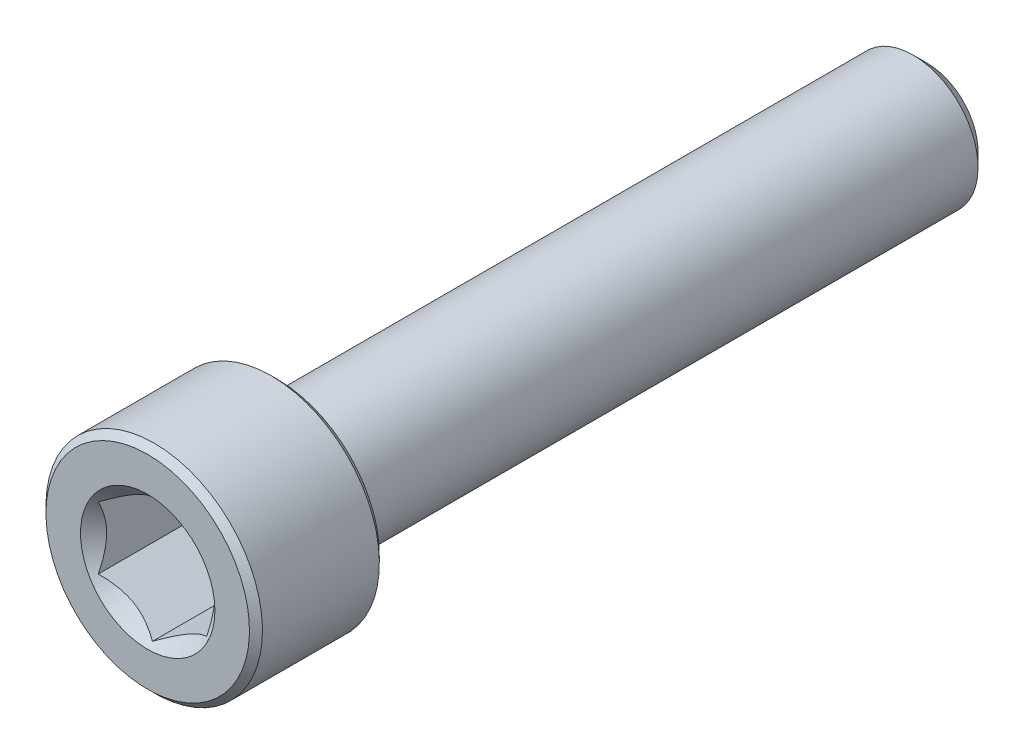
from build123d import *

# Parameters (mm, degrees)
CUT_EXTRUDE1_DEPTH = 5
SKETCH4_R          = 3.103257697
CUT_EXTRUDE2_DEPTH = 5
CUT_EXTRUDE2_DRAFT = -45


with BuildPart() as part:
    # Sketch2 → Revolve1 (revolve)
    with BuildSketch(Plane(origin=(0, 0, 0), x_dir=(0, 0, -1), z_dir=(1, 0, 0))):
        with BuildLine():
            Line((-18, 0), (-18, 4.7))
            Line((-18, 4.7), (-17.7, 5))
            Line((-17.7, 5), (-12.3, 5))
            Line((-12.3, 5), (-12, 4.7))
            Line((-12, 4.7), (-12, 3.3))
            ThreePointArc((-12, 3.3), (-11.912132034, 3.087867966), (-11.7, 3))
            Line((-11.7, 3), (17.350480947, 3))
            Line((17.350480947, 3), (18, 2.350480947))
            Line((18, 2.350480947), (18, 0))
            Line((18, 0), (-18, 0))
        make_face()
    revolve(axis=Axis((0, 0, -18), (0, 0, 1)))

    # Sketch3 → Cut-Extrude1 (cut)
    with BuildSketch(Plane.XY.offset(18)):
        Polygon((2.5, -1.443375673), (2.5, 1.443375673), (0, 2.886751346), (-2.5, 1.443375673), (-2.5, -1.443375673), (0, -2.886751346), align=None)
    extrude(amount=-CUT_EXTRUDE1_DEPTH, mode=Mode.SUBTRACT)


with BuildPart() as cut_extrude2_tool:
    # Sketch4 → Cut-Extrude2 (with draft: the straight prism first)
    with BuildSketch(Plane.XY.offset(18)):
        Circle(SKETCH4_R)
    extrude(amount=-CUT_EXTRUDE2_DEPTH)
    # Cut-Extrude2: the draft: its side faces are tilted about the plane it starts from
    cut_extrude2_sides = [cut_extrude2_tool.faces().sort_by_distance(p)[0] for p in [
        (-3.103257697, 0, 15.5),
    ]]
    draft(cut_extrude2_sides, Plane.XY.offset(18), CUT_EXTRUDE2_DRAFT)


with BuildPart() as part_1:
    add(part.part)

    # Cut-Extrude2: cut by cut_extrude2_tool
    add(cut_extrude2_tool.part, mode=Mode.SUBTRACT)


solid = part_1.part
